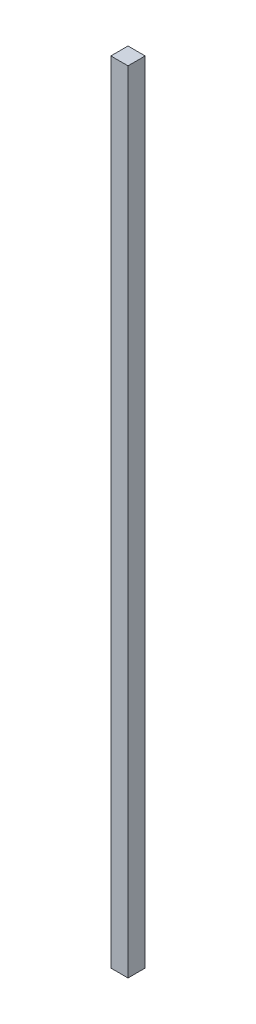
from build123d import *

# Parameters (mm, degrees)
ESQUISSE1_W        = 10
ESQUISSE1_H        = 460
BOSS_EXTRU_1_DEPTH = 10


with BuildPart() as part:
    # Esquisse1 → Boss.-Extru.1 (new body)
    with BuildSketch(Plane.XY):
        with Locations((-35.447603383, -198.035714286)):
            Rectangle(ESQUISSE1_W, ESQUISSE1_H)
    extrude(amount=BOSS_EXTRU_1_DEPTH)


solid = part.part
